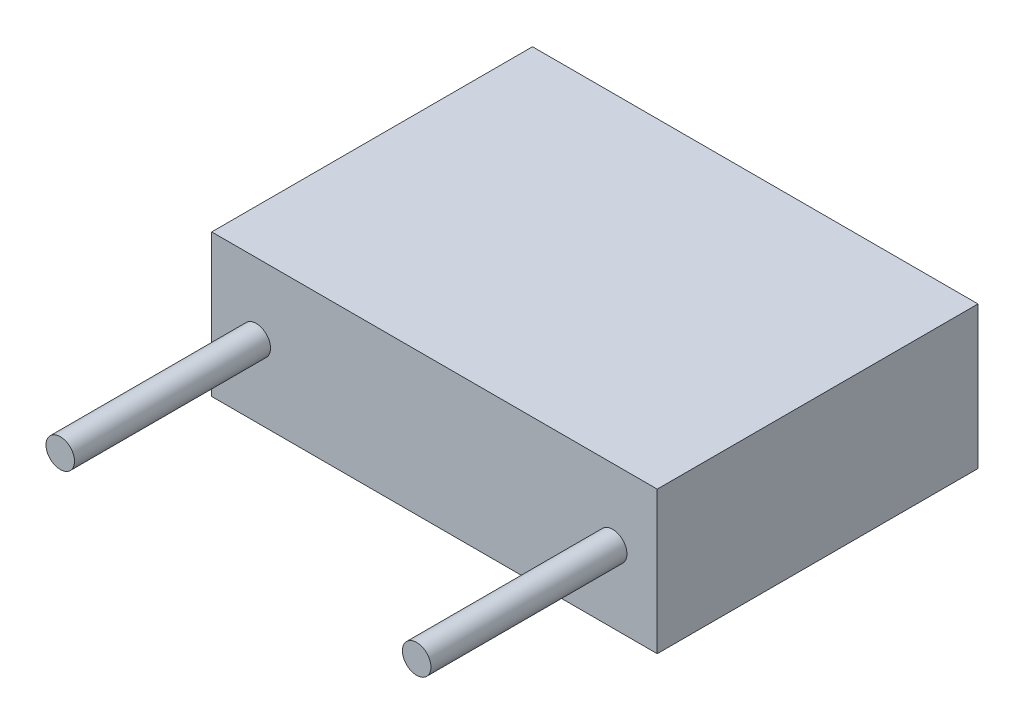
from build123d import *

# Parameters (mm, degrees)
SKETCH_1_W      = 12.5
SKETCH_1_H      = 4
EXTRUDE_1_DEPTH = 9
SKETCH_2_R      = 0.4
EXTRUDE_2_DEPTH = 5.5


with BuildPart() as part:
    # Эскиз1 → Бобышка-Вытянуть1 (new body)
    with BuildSketch(Plane.XY):
        with Locations((6.25, 2)):
            Rectangle(SKETCH_1_W, SKETCH_1_H)
    extrude(amount=EXTRUDE_1_DEPTH)

    # Эскиз2 → Бобышка-Вытянуть2 (add)
    with BuildSketch(Plane.XY.offset(9)):
        with Locations((1.25, 2)):
            Circle(SKETCH_2_R)
        with Locations((11.25, 2)):
            Circle(SKETCH_2_R)
    extrude(amount=EXTRUDE_2_DEPTH)


solid = part.part
